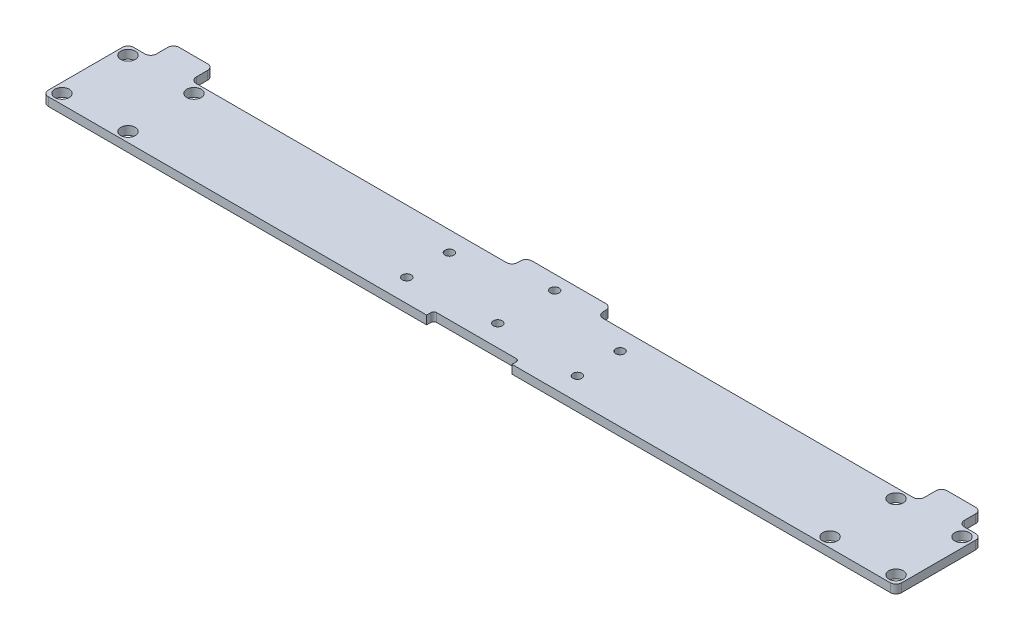
from build123d import *

# Parameters (mm, degrees)
CROQUIS1_R              = 2.55
CROQUIS1_R_2            = 1.55
SALIENTE_EXTRUIR1_DEPTH = 3
REDONDEO2_R             = 2
CORTAR_EXTRUIR1_DEPTH   = 3


with BuildPart() as part:
    # Croquis1 → Saliente-Extruir1 (new body)
    with BuildSketch(Plane(origin=(0, 0, 0), x_dir=(1, 0, 0), z_dir=(0, 1, 0))):
        Polygon((0, 0), (300, 0), (300, 30), (292, 30), (292, 38), (278, 38), (278, 30), (165, 30), (165, 35), (135, 35), (135, 30), (22, 30), (22, 38), (8, 38), (8, 30), (0, 30), align=None)
        with Locations((3.4, 26.6)):
            Circle(CROQUIS1_R, mode=Mode.SUBTRACT)
        with Locations((26.6, 26.6)):
            Circle(CROQUIS1_R, mode=Mode.SUBTRACT)
        with Locations((26.6, 3.4)):
            Circle(CROQUIS1_R, mode=Mode.SUBTRACT)
        with Locations((3.4, 3.4)):
            Circle(CROQUIS1_R, mode=Mode.SUBTRACT)
        with Locations((273.4, 3.4)):
            Circle(CROQUIS1_R, mode=Mode.SUBTRACT)
        with Locations((296.6, 3.4)):
            Circle(CROQUIS1_R, mode=Mode.SUBTRACT)
        with Locations((296.6, 26.6)):
            Circle(CROQUIS1_R, mode=Mode.SUBTRACT)
        with Locations((273.4, 26.6)):
            Circle(CROQUIS1_R, mode=Mode.SUBTRACT)
        with Locations((150, 30)):
            Circle(CROQUIS1_R_2, mode=Mode.SUBTRACT)
        with Locations((150, 10)):
            Circle(CROQUIS1_R_2, mode=Mode.SUBTRACT)
        with Locations((120, 23)):
            Circle(CROQUIS1_R_2, mode=Mode.SUBTRACT)
        with Locations((120, 8)):
            Circle(CROQUIS1_R_2, mode=Mode.SUBTRACT)
        with Locations((180, 8)):
            Circle(CROQUIS1_R_2, mode=Mode.SUBTRACT)
        with Locations((180, 23)):
            Circle(CROQUIS1_R_2, mode=Mode.SUBTRACT)
    extrude(amount=SALIENTE_EXTRUIR1_DEPTH)

    # Redondeo2
    redondeo2_edges = [part.edges().sort_by_distance(p)[0] for p in [
        (0, 1.5, -30),
        (8, 1.5, -30),
        (8, 1.5, -38),
        (22, 1.5, -38),
        (22, 1.5, -30),
        (135, 1.5, -30),
        (135, 1.5, -35),
        (165, 1.5, -35),
        (165, 1.5, -30),
        (278, 1.5, -30),
        (278, 1.5, -38),
        (292, 1.5, -38),
        (292, 1.5, -30),
        (300, 1.5, -30),
        (300, 1.5, 0),
        (0, 1.5, 0),
    ]]
    fillet(redondeo2_edges, radius=REDONDEO2_R)

    # Croquis2 → Cortar-Extruir1 (cut)
    with BuildSketch(Plane(origin=(0, 3, 0), x_dir=(1, 0, 0), z_dir=(0, 1, 0))):
        with BuildLine():
            Line((135, 0), (165, 0))
            Line((165, 0), (165, 1.5))
            ThreePointArc((165, 1.5), (164.707106781, 2.207106781), (164, 2.5))
            Line((164, 2.5), (136, 2.5))
            ThreePointArc((136, 2.5), (135.292893219, 2.207106781), (135, 1.5))
            Line((135, 1.5), (135, 0))
        make_face()
    extrude(amount=-CORTAR_EXTRUIR1_DEPTH, mode=Mode.SUBTRACT)


solid = part.part
